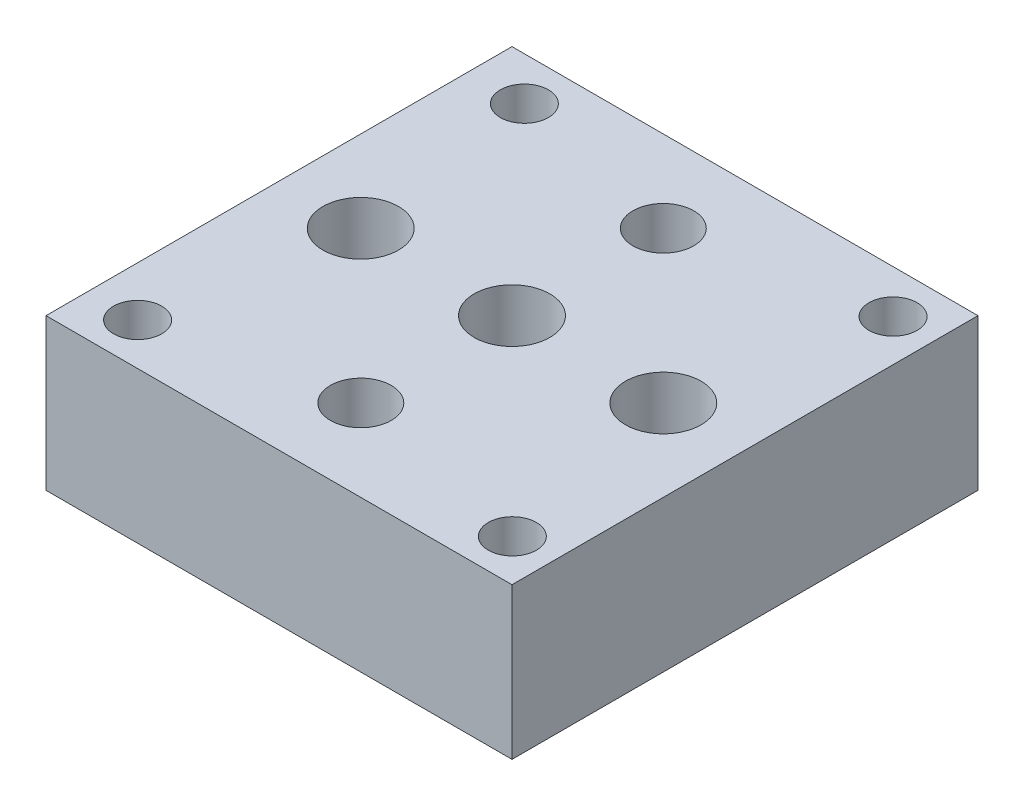
from build123d import *

# Parameters (mm, degrees)
SKETCH1_W                       = 39.116
SKETCH1_H                       = 39.116
BOSS_EXTRUDE1_DEPTH             = 12.7
F_21_0_159_DIAMETER_HOLE1_D     = 4.0386
F_21_0_159_DIAMETER_HOLE1_DEPTH = 12.7
F_1_4_0_25_DIAMETER_HOLE1_D     = 6.35
F_1_4_0_25_DIAMETER_HOLE1_DEPTH = 12.7
LPATTERN1_COUNT                 = 2
LPATTERN1_PITCH                 = 12.7
LPATTERN1_COL_COUNT             = 2
LPATTERN1_COL_PITCH             = 12.7
F_1_4_20_TAPPED_HOLE1_D         = 5.1054
F_1_4_20_TAPPED_HOLE1_DEPTH     = 12.7


with BuildPart() as part:
    # Sketch1 → Boss-Extrude1 (new body)
    with BuildSketch(Plane(origin=(0, 0, 0), x_dir=(1, 0, 0), z_dir=(0, 1, 0))):
        Rectangle(SKETCH1_W, SKETCH1_H)
    extrude(amount=BOSS_EXTRUDE1_DEPTH)

    # 21 _0.159_ Diameter Hole1
    with Locations(Plane(origin=(0, 12.7, 0), x_dir=(1, 0, 0), z_dir=(0, 1, 0))):
        with Locations((-14.89, 15.928), (-15.398, -16.028), (16.058, -16.028), (16.058, 15.928)):
            Hole(F_21_0_159_DIAMETER_HOLE1_D / 2, depth=F_21_0_159_DIAMETER_HOLE1_DEPTH)

    # 1_4 _0.25_ Diameter Hole1
    with Locations(Plane(origin=(0, 12.7, 0), x_dir=(1, 0, 0), z_dir=(0, 1, 0))):
        with Locations((0, 0)):
            f_1_4_0_25_diameter_hole1 = Hole(F_1_4_0_25_DIAMETER_HOLE1_D / 2, depth=F_1_4_0_25_DIAMETER_HOLE1_DEPTH)

    # LPattern1: 1_4 _0.25_ Diameter Hole1 ×2
    with Locations(*[(-i * LPATTERN1_PITCH, 0, 0) for i in range(1, LPATTERN1_COUNT)]):
        add(f_1_4_0_25_diameter_hole1, mode=Mode.SUBTRACT)

    # LPattern1 col: 1_4 _0.25_ Diameter Hole1 ×2
    with Locations(*[(i * LPATTERN1_COL_PITCH, 0, 0) for i in range(1, LPATTERN1_COL_COUNT)]):
        add(f_1_4_0_25_diameter_hole1, mode=Mode.SUBTRACT)

    # 1_4-20 Tapped Hole1
    with Locations(Plane(origin=(0, 12.7, 0), x_dir=(1, 0, 0), z_dir=(0, 1, 0))):
        with Locations((0, 12.7), (0, -12.690681966)):
            Hole(F_1_4_20_TAPPED_HOLE1_D / 2, depth=F_1_4_20_TAPPED_HOLE1_DEPTH)


solid = part.part
